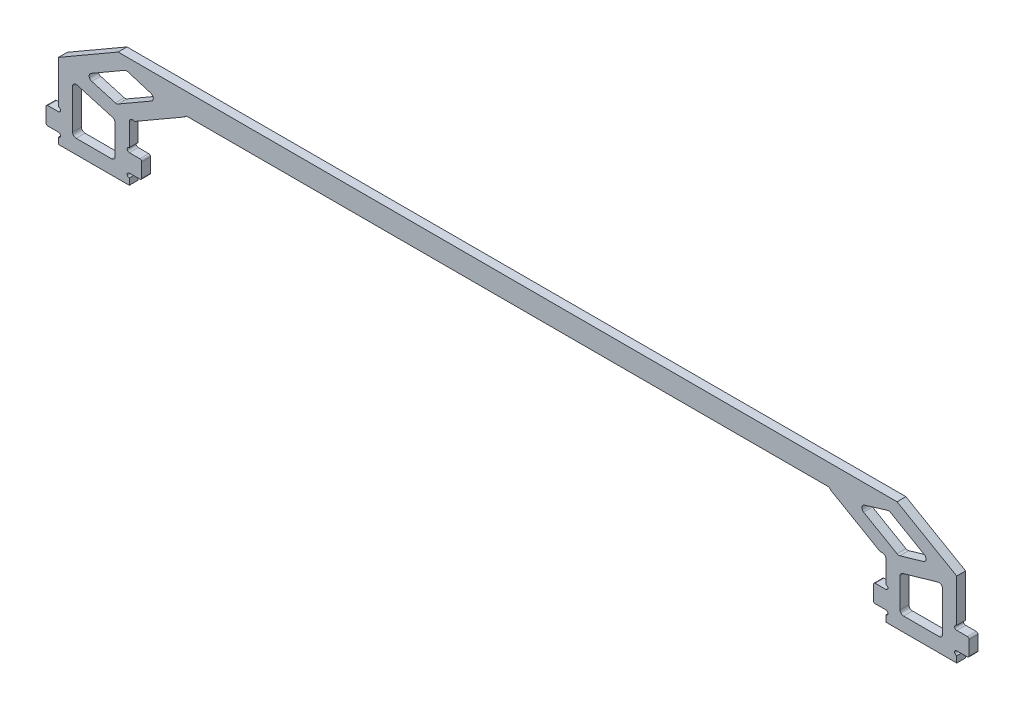
from build123d import *

# Parameters (mm, degrees)
EXTRUDE_1_DEPTH     = 1.25
SKETCH_2_W          = 3.5
SKETCH_2_H          = 5
EXTRUDE_2_DEPTH     = 2.5
SKETCH_3_R          = 0.6
CUT_EXTRUDE_1_DEPTH = 3.5
FILLET_1_R          = 0.5
CUT_EXTRUDE_3_DEPTH = 3.5
CUT_EXTRUDE_5_DEPTH = 3.5
CUT_EXTRUDE_6_DEPTH = 3.5
FILLET_4_R          = 1
SKETCH_12_R         = 1
CUT_EXTRUDE_7_DEPTH = 3.5
SKETCH_13_W         = 157.663481756
SKETCH_13_H         = 52.44668755
CUT_EXTRUDE_8_DEPTH = 3.5


with BuildPart() as part:
    # 草图1 → 凸台-拉伸1 (new body, symmetric)
    with BuildSketch(Plane.XY):
        Polygon((-126.75, 40), (-126.75, 0), (-106.75, 0), (-106.75, 15.5), (-90.295517328, 25), (101.265172443, 25), (106.75, 15.5), (106.75, 0), (126.75, 0), (126.75, 40), align=None)
    extrude(amount=EXTRUDE_1_DEPTH, both=True)

    # 草图2 → 凸台-拉伸2 (add)
    with BuildSketch(Plane.XY.offset(1.25)):
        with Locations((-105, 5.5)):
            Rectangle(SKETCH_2_W, SKETCH_2_H)
        with Locations((105, 5.5)):
            Rectangle(SKETCH_2_W, SKETCH_2_H)
        with Locations((-128.5, 5.5)):
            Rectangle(SKETCH_2_W, SKETCH_2_H)
        with Locations((128.5, 5.5)):
            Rectangle(SKETCH_2_W, SKETCH_2_H)
    extrude(amount=-EXTRUDE_2_DEPTH)

    # 草图3 → 切除-拉伸1 (cut, through all)
    with BuildSketch(Plane.XY.offset(1.25)):
        with Locations((-106.75, 8.6)):
            Circle(SKETCH_3_R)
        with Locations((-106.75, 2.4)):
            Circle(SKETCH_3_R)
        with Locations((106.75, 8.6)):
            Circle(SKETCH_3_R)
        with Locations((106.75, 2.4)):
            Circle(SKETCH_3_R)
        with Locations((-126.75, 8.6)):
            Circle(SKETCH_3_R)
        with Locations((-126.75, 2.4)):
            Circle(SKETCH_3_R)
        with Locations((126.75, 8.6)):
            Circle(SKETCH_3_R)
        with Locations((126.75, 2.4)):
            Circle(SKETCH_3_R)
    extrude(amount=-CUT_EXTRUDE_1_DEPTH, mode=Mode.SUBTRACT)

    # 圆角1
    fillet_1_edges = [part.edges().sort_by_distance(p)[0] for p in [
        (-103.25, 8, 0),
        (-103.25, 3, 0),
        (103.25, 3, 0),
        (103.25, 8, 0),
        (-130.25, 3, 0),
        (-130.25, 8, 0),
        (130.25, 8, 0),
        (130.25, 3, 0),
    ]]
    fillet(fillet_1_edges, radius=FILLET_1_R)

    # 草图7 → 切除-拉伸3 (cut, through all)
    with BuildSketch(Plane.XY.offset(1.25)):
        Polygon((-126.75, 21.273502692), (-94.314755215, 40), (-126.75, 40), align=None)
        Polygon((109.925426481, 40), (126.75, 40), (126.75, 10.858983849), align=None)
    extrude(amount=-CUT_EXTRUDE_3_DEPTH, mode=Mode.SUBTRACT)

    # 草图10 → 切除-拉伸5 (cut, through all)
    with BuildSketch(Plane.XY.offset(1.25)):
        Polygon((-109.903212483, 31), (59.199644147, 31), (69.925426481, 40), (-94.314755215, 40), align=None)
    extrude(amount=-CUT_EXTRUDE_5_DEPTH, mode=Mode.SUBTRACT)

    # 草图11 → 切除-拉伸6 (cut, through all)
    with BuildSketch(Plane.XY.offset(1.25)):
        Polygon((-107.634159118, 27.691236417), (-119.613891029, 20.774734974), (-110.280557696, 18.080433718), (-98.483901379, 24.891236417), align=None)
        Polygon((-122.75, 17.516719654), (-122.75, 4), (-110.75, 4), (-110.75, 14.052618039), align=None)
        Polygon((122.75, 10.247330901), (122.75, 4), (110.75, 4), (110.75, 13.031940592), align=None)
    extrude(amount=-CUT_EXTRUDE_6_DEPTH, mode=Mode.SUBTRACT)

    # 圆角4
    fillet_4_edges = [part.edges().sort_by_distance(p)[0] for p in [
        (-107.634159118, 27.691236417, 0),
        (-98.483901379, 24.891236417, 0),
        (-110.280557696, 18.080433718, 0),
        (-119.613891029, 20.774734974, 0),
        (-110.75, 4, 0),
        (-122.75, 4, 0),
        (-122.75, 17.516719654, 0),
        (-110.75, 14.052618039, 0),
        (122.75, 4, 0),
        (110.75, 4, 0),
        (110.75, 13.031940592, 0),
        (122.75, 10.247330901, 0),
    ]]
    fillet(fillet_4_edges, radius=FILLET_4_R)

    # 草图12 → 切除-拉伸7 (cut, through all)
    with BuildSketch(Plane.XY.offset(1.25)):
        with Locations((-90.295517328, 24)):
            Circle(SKETCH_12_R)
        with Locations((-105.75, 15.5)):
            Circle(SKETCH_12_R)
        with Locations((59.199644147, 32)):
            Circle(SKETCH_12_R)
        with Locations((101.265172443, 24)):
            Circle(SKETCH_12_R)
        with Locations((105.75, 15.5)):
            Circle(SKETCH_12_R)
    extrude(amount=-CUT_EXTRUDE_7_DEPTH, mode=Mode.SUBTRACT)

    # 草图13 → 切除-拉伸8 (cut, through all)
    with BuildSketch(Plane.XY.offset(1.25)):
        with Locations((78.831740878, 26.223343775)):
            Rectangle(SKETCH_13_W, SKETCH_13_H)
    extrude(amount=-CUT_EXTRUDE_8_DEPTH, mode=Mode.SUBTRACT)

    # 镜向2: part across plane


with BuildPart() as part_1:
    add(part.part)
    add(part.part.mirror(Plane(origin=(0, 52.44668755, -1.25), x_dir=(0, 0, 1), z_dir=(-1, 0, 0))))


solid = part_1.part
